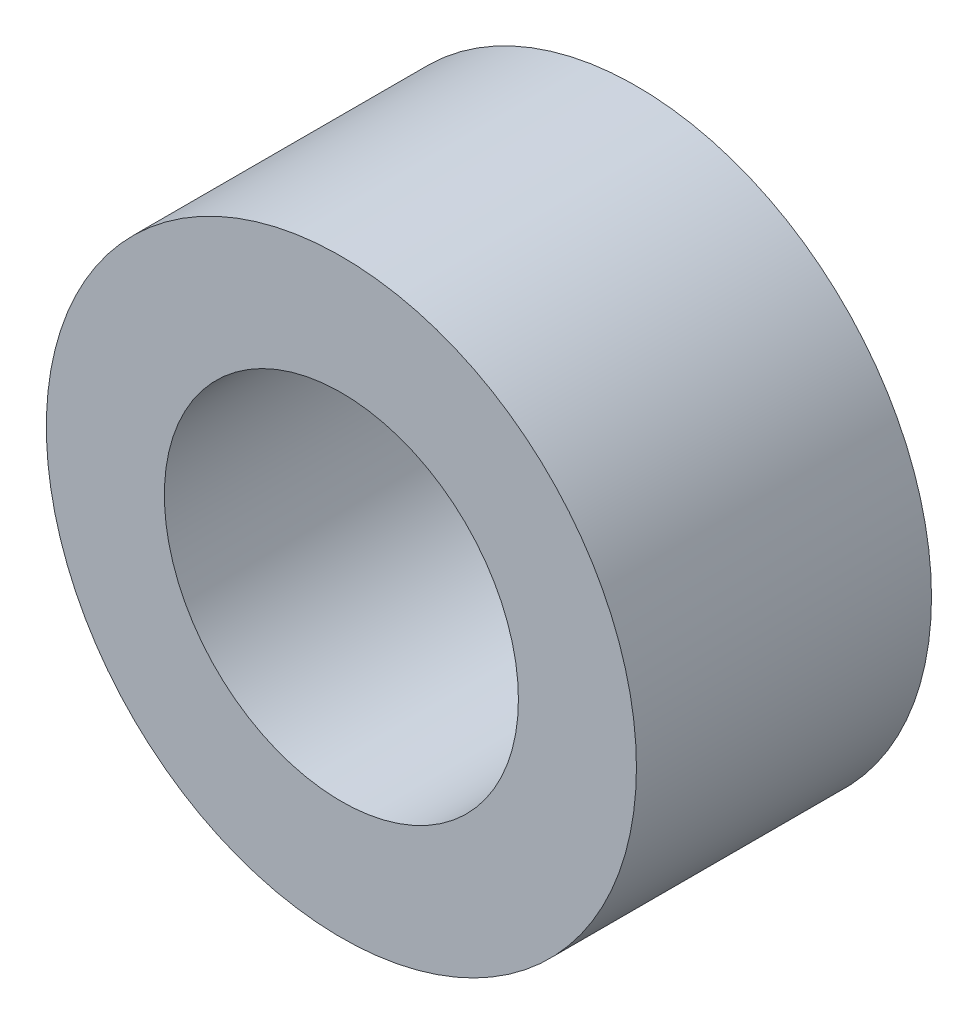
from build123d import *

# Parameters (mm, degrees)
SKETCH_1_R      = 2.5
SKETCH_1_R_2    = 1.5
EXTRUDE_1_DEPTH = 2.5


with BuildPart() as part:
    # 草图1 → 凸台-拉伸1 (new body)
    with BuildSketch(Plane.XY):
        Circle(SKETCH_1_R)
        Circle(SKETCH_1_R_2, mode=Mode.SUBTRACT)
    extrude(amount=EXTRUDE_1_DEPTH)


solid = part.part
